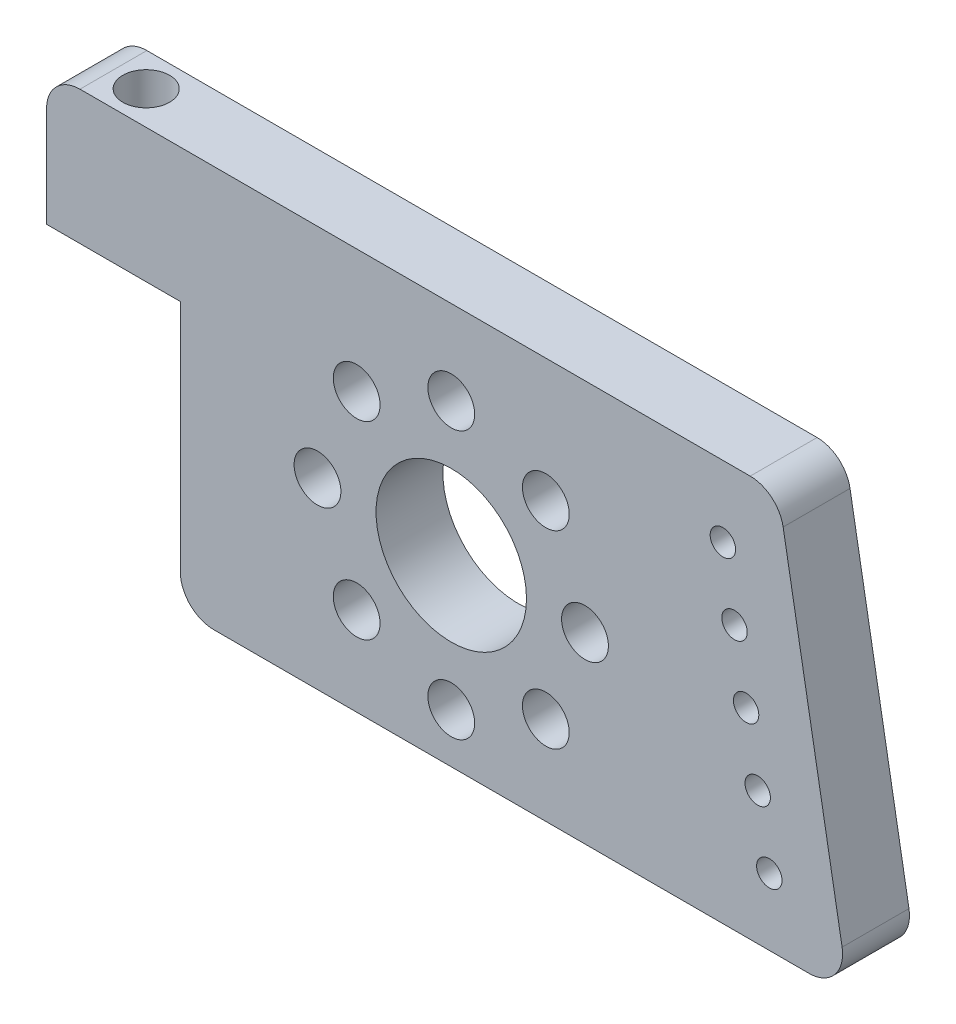
from build123d import *

# Parameters (mm, degrees)
SKETCH1_R              = 14.2875
BOSS_EXTRUDE1_DEPTH    = 12.7
SKETCH2_R              = 2.413
INITIAL_MOUNTING_DEPTH = 13.7
MOUNTING_PATTERN_COUNT = 8
FILLET1_R              = 6.35
SKETCH3_R              = 2.413
CUT_EXTRUDE1_DEPTH     = 26.4
CUT_EXTRUDE2_START     = -12.7
SKETCH3_3_R            = 4.445
SKETCH3_3_R_2          = 2.413
CUT_EXTRUDE2_DEPTH     = 13.7
SKETCH4_R              = 2.413
CUT_EXTRUDE3_DEPTH     = 13.7
LPATTERN1_COUNT        = 5
LPATTERN1_PITCH        = 12.7
CUT_EXTRUDE4_START     = -12.7
SKETCH5_R              = 4.445
CUT_EXTRUDE4_DEPTH     = 6.35
CIRPATTERN1_COUNT      = 8


with BuildPart() as part:
    # Sketch1 → Boss-Extrude1 (new body)
    with BuildSketch(Plane.XY):
        Polygon((-63.5, -42.607736074), (63.5, -42.607736074), (50.06388407, 33.592263926), (-50.06388407, 33.592263926), (-88.9, 33.592263926), (-88.9, 8.192263926), (-63.5, 8.192263926), align=None)
        with Locations((-12.04252973, -7.815733859)):
            Circle(SKETCH1_R, mode=Mode.SUBTRACT)
    extrude(amount=BOSS_EXTRUDE1_DEPTH)

    # Sketch2 → Initial Mounting (cut, through all)
    with BuildSketch(Plane.XY.offset(12.7)):
        with Locations((-12.04252973, -33.215733859)):
            Circle(SKETCH2_R)
    initial_mounting = extrude(amount=-INITIAL_MOUNTING_DEPTH, mode=Mode.SUBTRACT)

    # Mounting Pattern: Initial Mounting ×8 about axis
    mounting_pattern_axis = Axis((-12.04252973, -7.815733859, 0), (0, 0, 1))
    for i in range(1, MOUNTING_PATTERN_COUNT):
        add(initial_mounting.rotate(mounting_pattern_axis, i * 360 / MOUNTING_PATTERN_COUNT), mode=Mode.SUBTRACT)

    # Fillet1
    fillet1_edges = [part.edges().sort_by_distance(p)[0] for p in [
        (63.5, -42.607736074, 6.35),
        (-63.5, -42.607736074, 6.35),
        (-88.9, 33.592263926, 6.35),
        (50.06388407, 33.592263926, 6.35),
    ]]
    fillet(fillet1_edges, radius=FILLET1_R)

    # Sketch3 → Cut-Extrude1 (cut, through all)
    with BuildSketch(Plane.XZ.offset(-8.192263926)):
        with Locations((-76.327, 6.35)):
            Circle(SKETCH3_R)
    extrude(amount=-CUT_EXTRUDE1_DEPTH, mode=Mode.SUBTRACT)

    # Sketch3_3 → Cut-Extrude2 (cut, through all)
    with BuildSketch(Plane.XZ.offset(-8.192263926).offset(CUT_EXTRUDE2_START)):
        with Locations((-76.327, 6.35)):
            Circle(SKETCH3_3_R)
        with Locations((-76.327, 6.35)):
            Circle(SKETCH3_3_R_2, mode=Mode.SUBTRACT)
    extrude(amount=-CUT_EXTRUDE2_DEPTH, mode=Mode.SUBTRACT)

    # Sketch4 → Cut-Extrude3 (cut, through all)
    with BuildSketch(Plane.XY.offset(12.7)):
        with Locations((48.364729374, -29.907736074)):
            Circle(SKETCH4_R)
    cut_extrude3 = extrude(amount=-CUT_EXTRUDE3_DEPTH, mode=Mode.SUBTRACT)

    # LPattern1: Cut-Extrude3 ×5
    with Locations(*[Vector(-0.173648178, 0.984807753, 0) * (i * LPATTERN1_PITCH) for i in range(1, LPATTERN1_COUNT)]):
        add(cut_extrude3, mode=Mode.SUBTRACT)

    # Sketch5 → Cut-Extrude4 (cut)
    with BuildSketch(Plane(origin=(0, 0, 0), x_dir=(-1, 0, 0), z_dir=(0, 0, -1)).offset(CUT_EXTRUDE4_START)):
        with Locations((12.04252973, 17.584266141)):
            Circle(SKETCH5_R)
    cut_extrude4 = extrude(amount=CUT_EXTRUDE4_DEPTH, mode=Mode.SUBTRACT)

    # CirPattern1: Cut-Extrude4 ×8 about axis
    cirpattern1_axis = Axis((-12.04252973, -7.815733859, 0), (0, 0, 1))
    for i in range(1, CIRPATTERN1_COUNT):
        add(cut_extrude4.rotate(cirpattern1_axis, i * 360 / CIRPATTERN1_COUNT), mode=Mode.SUBTRACT)


solid = part.part
